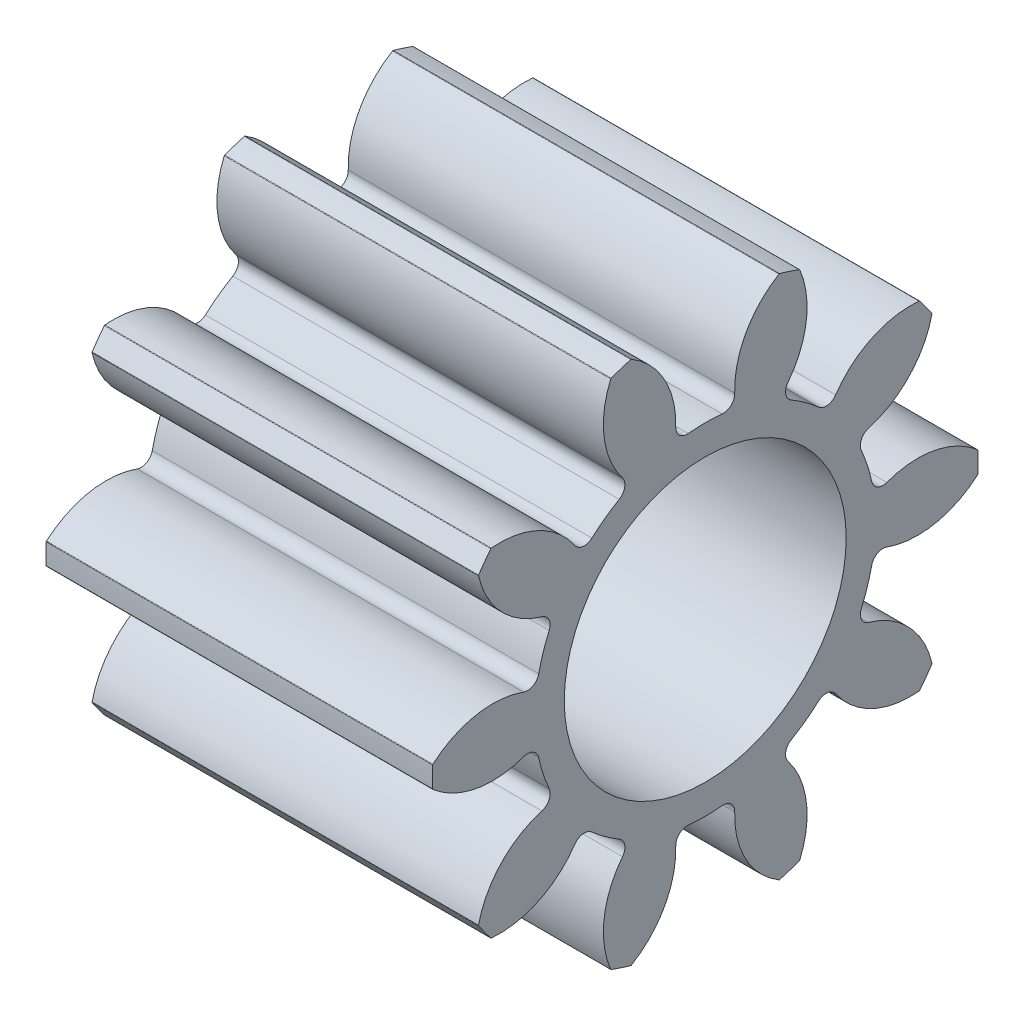
from build123d import *

# Parameters (mm, degrees)
BASPROSKE_W                = 8.5
BASPROSKE_H                = 6
TOOTHCUT_DEPTH             = 13.010412149
BREAKS_R                   = 0.02
ROOTFILLETS_R              = 0.251
TEETHCUTS_COUNT            = 10
TEETHCUTS_ANGLE            = 324
BREAKS_OF_TEETHCUTS_R      = 0.02
ROOTFILLETS_OF_TEETHCUTS_R = 0.251
BORSKE_R                   = 1.8
BORE_DEPTH                 = 50.0000508
SKETCH3_R                  = 2.5
SKETCH3_R_2                = 1.8
BOSS_EXTRUDE1_DEPTH        = 1
SKETCH4_R                  = 3.1
CUT_EXTRUDE2_DEPTH         = 5
CHAMFER2_SIZE              = 0.5


with BuildPart() as part:
    # BasProSke → Base-Revolve (revolve)
    with BuildSketch(Plane(origin=(0, 0, 0), x_dir=(1, 0, 0), z_dir=(0, 1, 0)), mode=Mode.PRIVATE) as base_revolve_sk:
        with Locations((4.25, 3)):
            Rectangle(BASPROSKE_W, BASPROSKE_H)
    revolve(base_revolve_sk.sketch.rotate(Axis((-10, 0, 0), (1, 0, 0)), 180), axis=Axis((-10, 0, 0), (1, 0, 0)))

    # TooCutSke → ToothCut (cut, through all)
    with BuildSketch(Plane(origin=(0, 0, 0), x_dir=(0, 0, -1), z_dir=(1, 0, 0))):
        with BuildLine():
            ThreePointArc((0.680948119, 3.686639481), (0, 3.749), (-0.680948119, 3.686639481))
            ThreePointArc((-0.680948119, 3.686639481), (-0.833594699, 4.896067871), (-1.659981216, 5.7922282))
            ThreePointArc((-1.659981216, 5.7922282), (0, 6.0254), (1.659981216, 5.7922282))
            ThreePointArc((1.659981216, 5.7922282), (0.833594699, 4.896067871), (0.680948119, 3.686639481))
        make_face()
    toothcut = extrude(amount=TOOTHCUT_DEPTH, mode=Mode.SUBTRACT)

    # Breaks
    breaks_edges = [part.edges().sort_by_distance(p)[0] for p in [
        (4.25, 5.774516397, -1.629404918),
        (4.25, 5.774516397, 1.629404918),
    ]]
    fillet(breaks_edges, radius=BREAKS_R)

    # RootFillets
    rootfillets_edges = [part.edges().sort_by_distance(p)[0] for p in [
        (4.25, 3.686639481, -0.680948119),
        (4.25, 3.686639481, 0.680948119),
    ]]
    fillet(rootfillets_edges, radius=ROOTFILLETS_R)

    # TeethCuts: ToothCut ×10 about axis
    teethcuts_axis = Axis((-10, 0, 0), (1, 0, 0))
    for i in range(1, TEETHCUTS_COUNT):
        add(toothcut.rotate(teethcuts_axis, i * TEETHCUTS_ANGLE / (TEETHCUTS_COUNT - 1)), mode=Mode.SUBTRACT)

    # Breaks of TeethCuts
    breaks_of_teethcuts_edges = [part.edges().sort_by_distance(p)[0] for p in [
        (4.25, 5.62942208, 2.075959308),
        (4.25, 3.713941719, 4.712391846),
        (4.25, 3.334079865, 4.988377637),
        (4.25, 0.234767536, 5.995405258),
        (4.25, -0.234767536, 5.995405258),
        (4.25, -3.334079865, 4.988377637),
        (4.25, -3.713941719, 4.712391846),
        (4.25, -5.62942208, 2.075959308),
        (4.25, -5.774516397, 1.629404918),
        (4.25, -5.774516397, -1.629404918),
        (4.25, -5.62942208, -2.075959308),
        (4.25, -3.713941719, -4.712391846),
        (4.25, -3.334079865, -4.988377637),
        (4.25, -0.234767536, -5.995405258),
        (4.25, 0.234767536, -5.995405258),
        (4.25, 3.334079865, -4.988377637),
        (4.25, 3.713941719, -4.712391846),
        (4.25, 5.62942208, -2.075959308),
    ]]
    fillet(breaks_of_teethcuts_edges, radius=BREAKS_OF_TEETHCUTS_R)

    # RootFillets of TeethCuts
    rootfillets_of_teethcuts_edges = [part.edges().sort_by_distance(p)[0] for p in [
        (4.25, 3.382805254, 1.616053717),
        (4.25, 2.58230273, 2.717850918),
        (4.25, 1.786854397, 3.29577796),
        (4.25, 0.491614106, 3.716627042),
        (4.25, -0.491614106, 3.716627042),
        (4.25, -1.786854397, 3.29577796),
        (4.25, -2.58230273, 2.717850918),
        (4.25, -3.382805254, 1.616053717),
        (4.25, -3.686639481, 0.680948119),
        (4.25, -3.686639481, -0.680948119),
        (4.25, -3.382805254, -1.616053717),
        (4.25, -2.58230273, -2.717850918),
        (4.25, -1.786854397, -3.29577796),
        (4.25, -0.491614106, -3.716627042),
        (4.25, 0.491614106, -3.716627042),
        (4.25, 1.786854397, -3.29577796),
        (4.25, 2.58230273, -2.717850918),
        (4.25, 3.382805254, -1.616053717),
    ]]
    fillet(rootfillets_of_teethcuts_edges, radius=ROOTFILLETS_OF_TEETHCUTS_R)

    # BorSke → Bore (cut, symmetric)
    with BuildSketch(Plane(origin=(0, 0, 0), x_dir=(0, 0, -1), z_dir=(1, 0, 0))):
        with Locations(Location((0, 0, 0), (0, 0, 180))):
            Circle(BORSKE_R)
    extrude(amount=BORE_DEPTH, both=True, mode=Mode.SUBTRACT)

    # Sketch3 → Boss-Extrude1 (add)
    with BuildSketch(Plane.ZY):
        with Locations(Location((0, 0, 0), (0, 0, 180))):
            Circle(SKETCH3_R)
        Circle(SKETCH3_R_2, mode=Mode.SUBTRACT)
    extrude(amount=BOSS_EXTRUDE1_DEPTH)

    # Sketch4 → Cut-Extrude2 (cut)
    with BuildSketch(Plane(origin=(8.5, 0, 0), x_dir=(0, 0, -1), z_dir=(1, 0, 0))):
        Circle(SKETCH4_R)
    extrude(amount=-CUT_EXTRUDE2_DEPTH, mode=Mode.SUBTRACT)

    # Chamfer2
    chamfer2_edges = [part.edges().sort_by_distance(p)[0] for p in [
        (-1, 0, 2.5),
    ]]
    chamfer(chamfer2_edges, length=CHAMFER2_SIZE)


solid = part.part
